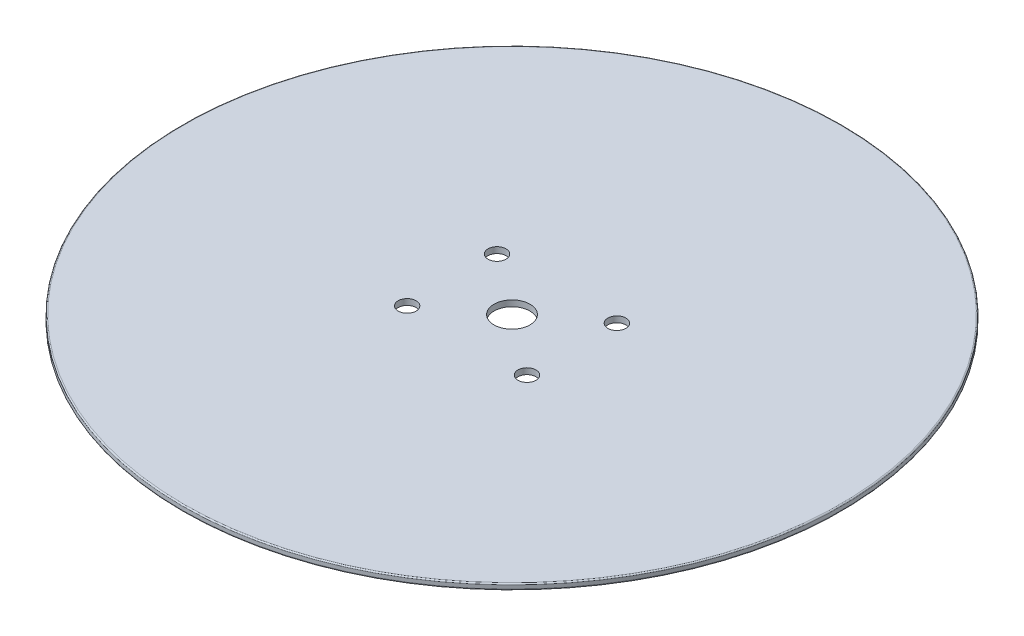
from build123d import *

# Parameters (mm, degrees)
SKETCH1_R           = 55
BOSS_EXTRUDE1_DEPTH = 1
FILLET2_R           = 0.2
SKETCH4_R           = 3
CUT_EXTRUDE2_DEPTH  = 2
SKETCH3_R           = 1.5
CUT_EXTRUDE3_DEPTH  = 2


with BuildPart() as part:
    # Sketch1 → Boss-Extrude1 (new body)
    with BuildSketch(Plane(origin=(0, 0, 0), x_dir=(1, 0, 0), z_dir=(0, 1, 0))):
        Circle(SKETCH1_R)
    extrude(amount=BOSS_EXTRUDE1_DEPTH)

    # Fillet2
    fillet2_edges = [part.edges().sort_by_distance(p)[0] for p in [
        (-55, 0, 0),
        (-55, 1, 0),
    ]]
    fillet(fillet2_edges, radius=FILLET2_R)

    # Sketch4 → Cut-Extrude2 (cut, through all)
    with BuildSketch(Plane(origin=(0, 1, 0), x_dir=(1, 0, 0), z_dir=(0, 1, 0))):
        Circle(SKETCH4_R)
    extrude(amount=-CUT_EXTRUDE2_DEPTH, mode=Mode.SUBTRACT)

    # Sketch3 → Cut-Extrude3 (cut, through all)
    with BuildSketch(Plane(origin=(0, 1, 0), x_dir=(1, 0, 0), z_dir=(0, 1, 0))):
        with Locations((-10, 7.5)):
            Circle(SKETCH3_R)
        with Locations((10, 7.5)):
            Circle(SKETCH3_R)
        with Locations((10, -7.5)):
            Circle(SKETCH3_R)
        with Locations((-10, -7.5)):
            Circle(SKETCH3_R)
    extrude(amount=-CUT_EXTRUDE3_DEPTH, mode=Mode.SUBTRACT)


solid = part.part
